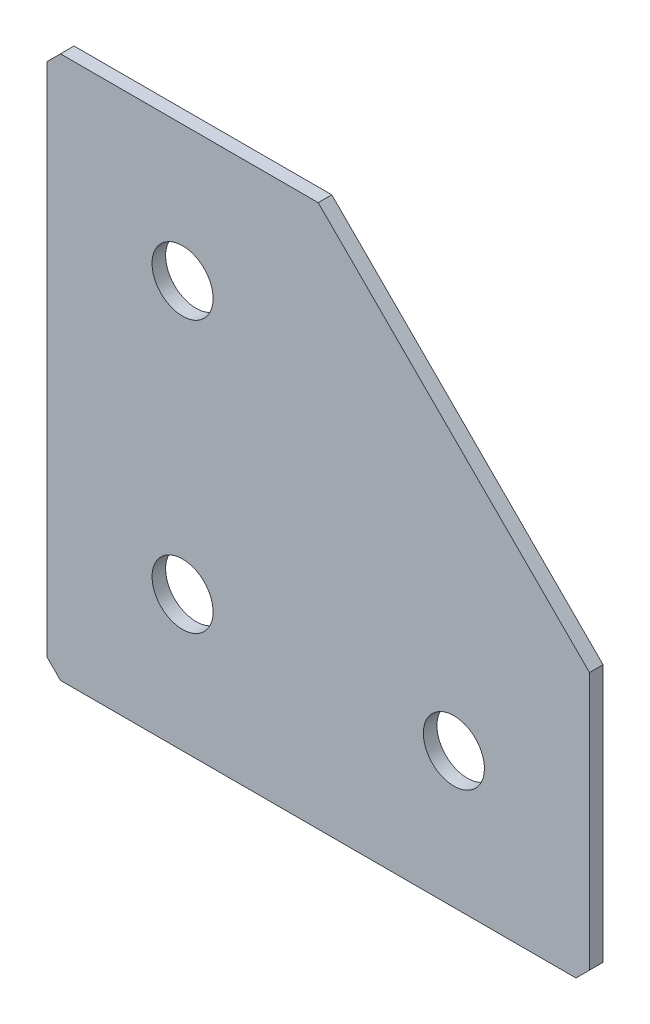
from build123d import *

# Parameters (mm, degrees)
EXTRUDE_1_DEPTH   = 2
HOLE_WIZARD_M81_D = 9
CHAMFER_1_SIZE    = 2


with BuildPart() as part:
    # Эскиз1 → Бобышка-Вытянуть1 (new body)
    with BuildSketch(Plane(origin=(0, 0, 0), x_dir=(1, 0, 0), z_dir=(0, 0, -1))):
        Polygon((0, 0), (0, 80), (80, 80), (80, 40), (40, 0), align=None)
    extrude(amount=EXTRUDE_1_DEPTH)

    # Отверстие с зазором M81 (through all)
    with Locations(Plane(origin=(0, 0, -2), x_dir=(1, 0, 0), z_dir=(0, 0, -1))):
        with Locations((20, 60), (20, 20), (60, 60)):
            Hole(HOLE_WIZARD_M81_D / 2)

    # Фаска1
    chamfer_1_edges = [part.edges().sort_by_distance(p)[0] for p in [
        (0, 0, -1),
        (0, -80, -1),
        (80, -80, -1),
    ]]
    chamfer(chamfer_1_edges, length=CHAMFER_1_SIZE)


solid = part.part
